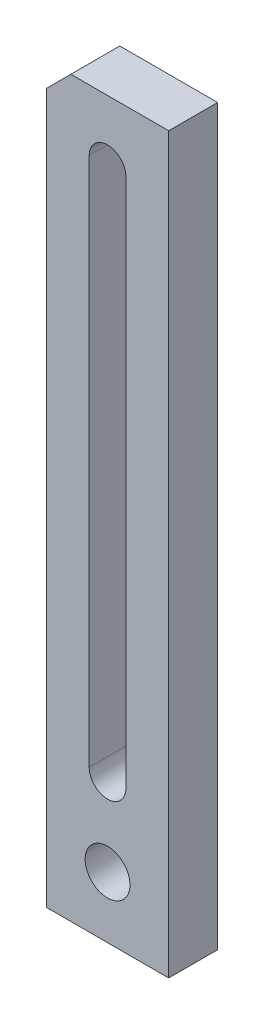
from build123d import *

# Parameters (mm, degrees)
SKETCH_1_W          = 30
SKETCH_1_H          = 180
EXTRUDE_1_DEPTH     = 12
SKETCH_2_R          = 5.5
CUT_EXTRUDE_1_DEPTH = 12
CHAMFER_1_SIZE      = 6


with BuildPart() as part:
    # 草图1 → 凸台-拉伸1 (new body)
    with BuildSketch(Plane.XY):
        Rectangle(SKETCH_1_W, SKETCH_1_H)
    extrude(amount=EXTRUDE_1_DEPTH)

    # 草图2 → 切除-拉伸1 (cut)
    with BuildSketch(Plane.XY.offset(12)):
        with Locations((0, -75)):
            Circle(SKETCH_2_R)
        with BuildLine():
            Line((4.5, 75), (4.5, -55))
            ThreePointArc((4.5, -55), (0, -59.5), (-4.5, -55))
            Line((-4.5, -55), (-4.5, 75))
            ThreePointArc((-4.5, 75), (0, 79.5), (4.5, 75))
        make_face()
    extrude(amount=-CUT_EXTRUDE_1_DEPTH, mode=Mode.SUBTRACT)

    # 倒角1
    chamfer_1_edges = [part.edges().sort_by_distance(p)[0] for p in [
        (-15, 90, 6),
    ]]
    chamfer(chamfer_1_edges, length=CHAMFER_1_SIZE)


solid = part.part
